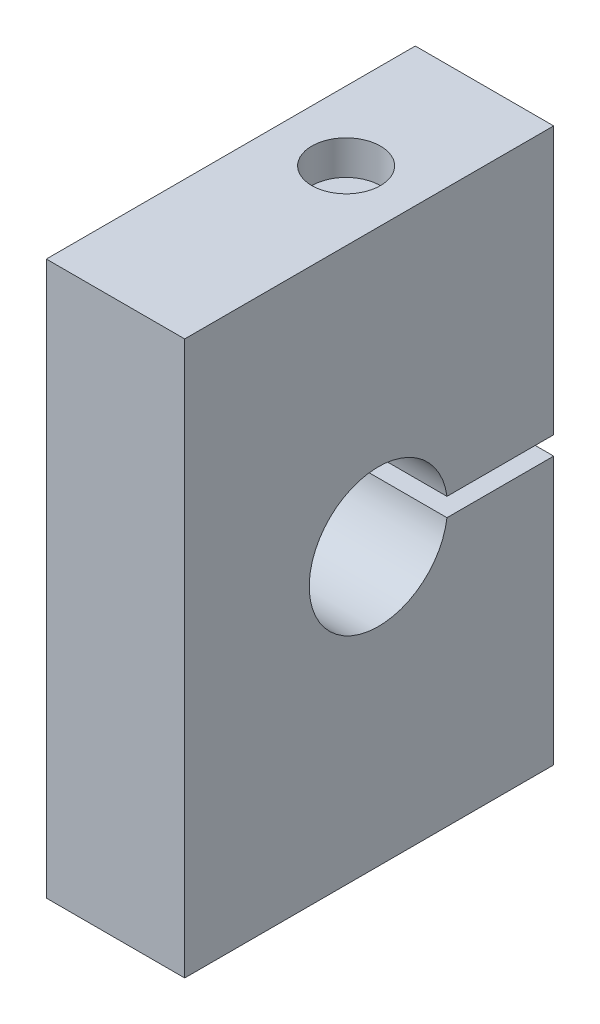
from build123d import *

# Parameters (mm, degrees)
BOSS_EXTRUDE1_DEPTH               = 19.05
F_1_4_20_TAPPED_HOLE1_D           = 5.1054
F_1_4_20_TAPPED_HOLE1_DEPTH       = 16.51
F_1_4_20_TAPPED_HOLE1_CSINK_D     = 6.3754
F_1_4_20_TAPPED_HOLE1_CSINK_ANGLE = 90
F_1_4_20_TAPPED_HOLE1_TIP         = 1.533816902
SKETCH3_R                         = 4.7244
CUT_EXTRUDE1_DEPTH                = 4.7244


with BuildPart() as part:
    # Sketch2 → Boss-Extrude1 (new body)
    with BuildSketch(Plane(origin=(0, 0, 0), x_dir=(0, 0, -1), z_dir=(1, 0, 0))):
        with BuildLine():
            Line((0, 0), (50.8, 0))
            Line((50.8, 0), (50.8, 36.83))
            Line((50.8, 36.83), (36.109953655, 36.83))
            ThreePointArc((36.109953655, 36.83), (17.145, 38.1), (36.109953655, 39.37))
            Line((36.109953655, 39.37), (50.8, 39.37))
            Line((50.8, 39.37), (50.8, 76.2))
            Line((50.8, 76.2), (0, 76.2))
            Line((0, 76.2), (0, 0))
        make_face()
    extrude(amount=BOSS_EXTRUDE1_DEPTH)

    # 1/4-20 Tapped Hole1
    with Locations(Plane(origin=(0, 0, 0), x_dir=(-1, 0, 0), z_dir=(0, -1, 0))):
        with Locations((-9.525, 12.7), (-9.525, 38.1)):
            CounterSinkHole(F_1_4_20_TAPPED_HOLE1_D / 2, F_1_4_20_TAPPED_HOLE1_CSINK_D / 2, depth=F_1_4_20_TAPPED_HOLE1_DEPTH, counter_sink_angle=F_1_4_20_TAPPED_HOLE1_CSINK_ANGLE)
            with Locations((0, 0, -(F_1_4_20_TAPPED_HOLE1_DEPTH + F_1_4_20_TAPPED_HOLE1_TIP / 2))):  # 118° drill point
                Cone(0, F_1_4_20_TAPPED_HOLE1_D / 2, F_1_4_20_TAPPED_HOLE1_TIP, mode=Mode.SUBTRACT)

    # Sketch3 → Cut-Extrude1 (cut)
    with BuildSketch(Plane(origin=(0, 76.2, 0), x_dir=(1, 0, 0), z_dir=(0, 1, 0))):
        with Locations((9.525, 31.75)):
            Circle(SKETCH3_R)
    extrude(amount=-CUT_EXTRUDE1_DEPTH, mode=Mode.SUBTRACT)


solid = part.part
